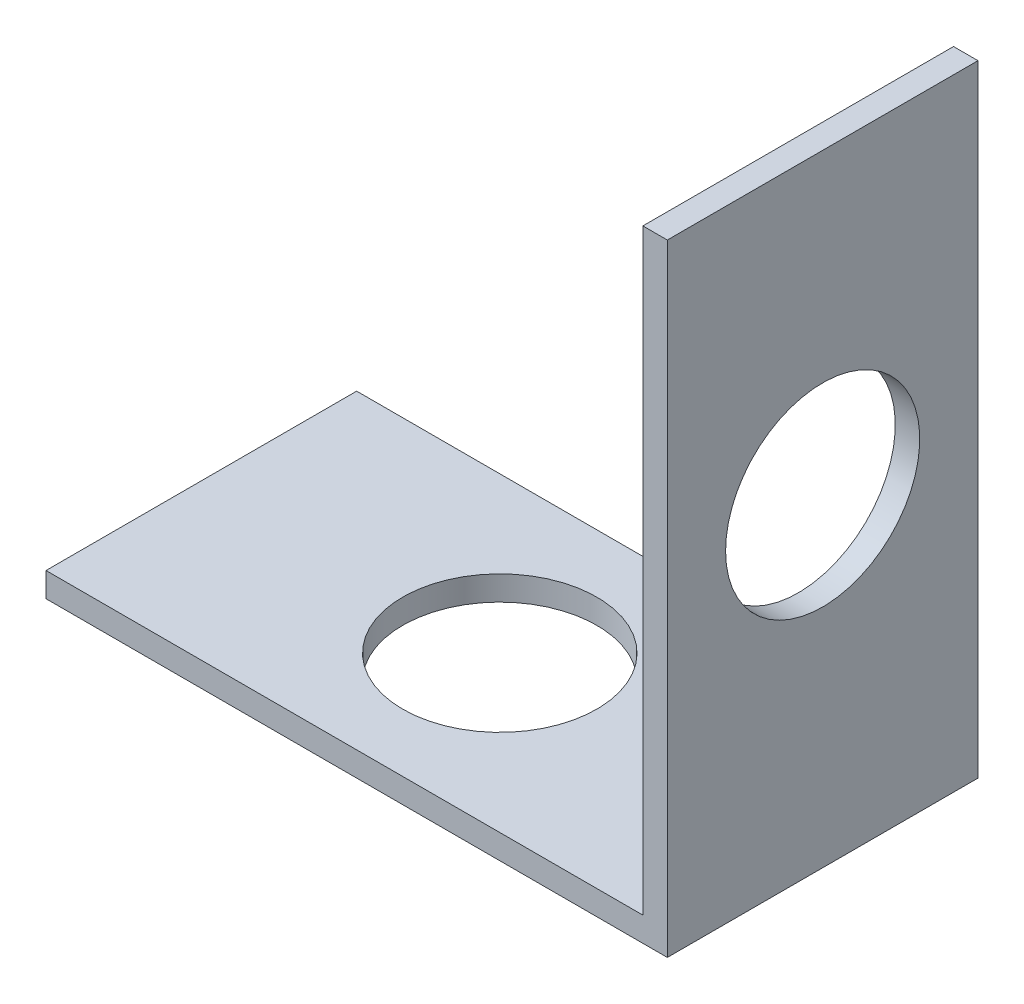
from build123d import *

# Parameters (mm, degrees)
BOSS_EXTRUDE1_DEPTH            = 6.35
F_5_16_0_3125_DIAMETER_HOLE1_D = 7.9375
F_5_16_0_3125_DIAMETER_HOLE2_D = 7.9375


with BuildPart() as part:
    # Sketch1 → Boss-Extrude1 (new body, symmetric)
    with BuildSketch(Plane.XY):
        Polygon((0, 0), (0, 25.4), (-1, 25.4), (-1, 1), (-25.4, 1), (-25.4, 0), align=None)
    extrude(amount=BOSS_EXTRUDE1_DEPTH, both=True)

    # 5/16 (0.3125) Diameter Hole1 (through all)
    with Locations(Plane.ZY.offset(1)):
        with Locations((0, 13.2)):
            Hole(F_5_16_0_3125_DIAMETER_HOLE1_D / 2)

    # 5/16 (0.3125) Diameter Hole2 (through all)
    with Locations(Plane(origin=(-13.2, 1, 0), x_dir=(1, 0, 0), z_dir=(0, 1, 0))):
        with Locations((0, 0)):
            Hole(F_5_16_0_3125_DIAMETER_HOLE2_D / 2)


solid = part.part
